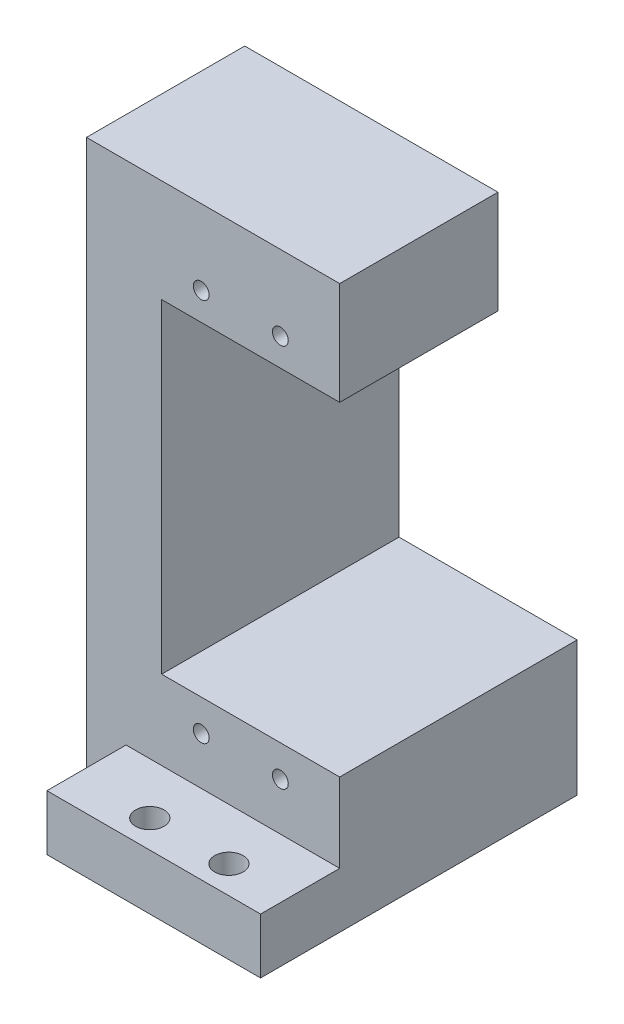
from build123d import *

# Parameters (mm, degrees)
SKETCH1_W           = 25
SKETCH1_H           = 40
BOSS_EXTRUDE1_DEPTH = 50
SKETCH2_W           = 22.5
SKETCH2_H           = 40
CUT_EXTRUDE1_DEPTH  = 25
SKETCH3_W           = 20
SKETCH3_H           = 10
CUT_EXTRUDE2_DEPTH  = 10
SKETCH5_R           = 1
CUT_EXTRUDE4_DEPTH  = 12
SKETCH6_W           = 25
SKETCH6_H           = 40
CUT_EXTRUDE5_DEPTH  = 8
SKETCH7_W           = 20
SKETCH7_H           = 22.5
CUT_EXTRUDE6_DEPTH  = 8
SKETCH8_R           = 1.8
CUT_EXTRUDE7_DEPTH  = 8
SKETCH12_W          = 10
SKETCH12_H          = 10
CUT_EXTRUDE9_DEPTH  = 10
SKETCH13_W          = 2.5
SKETCH13_H          = 40
BOSS_EXTRUDE2_DEPTH = 19
SKETCH14_W          = 40
SKETCH14_H          = 61
BOSS_EXTRUDE3_DEPTH = 2
SKETCH15_W          = 40
SKETCH15_H          = 3
BOSS_EXTRUDE4_DEPTH = 22.5
SKETCH16_W          = 10
SKETCH16_H          = 3
CUT_EXTRUDE10_DEPTH = 22.5
SKETCH17_W          = 10
SKETCH17_H          = 54
CUT_EXTRUDE11_DEPTH = 5.5
SKETCH18_W          = 27
SKETCH18_H          = 30
BOSS_EXTRUDE5_DEPTH = 10
SKETCH19_W          = 30
SKETCH19_H          = 71
BOSS_EXTRUDE6_DEPTH = 5
SKETCH20_W          = 32
SKETCH20_H          = 10
CUT_EXTRUDE12_DEPTH = 13


with BuildPart() as part:
    # Sketch1 → Boss-Extrude1 (new body)
    with BuildSketch(Plane(origin=(0, 0, 0), x_dir=(1, 0, 0), z_dir=(0, 1, 0))):
        with Locations((12.5, 20)):
            Rectangle(SKETCH1_W, SKETCH1_H)
    extrude(amount=BOSS_EXTRUDE1_DEPTH)

    # Sketch2 → Cut-Extrude1 (cut)
    with BuildSketch(Plane(origin=(0, 50, 0), x_dir=(1, 0, 0), z_dir=(0, 1, 0))):
        with Locations((13.75, 20)):
            Rectangle(SKETCH2_W, SKETCH2_H)
    extrude(amount=-CUT_EXTRUDE1_DEPTH, mode=Mode.SUBTRACT)

    # Sketch3 → Cut-Extrude2 (cut)
    with BuildSketch(Plane.XY):
        with Locations((12.5, 20)):
            Rectangle(SKETCH3_W, SKETCH3_H)
    extrude(amount=-CUT_EXTRUDE2_DEPTH, mode=Mode.SUBTRACT)

    # Sketch5 → Cut-Extrude4 (cut)
    with BuildSketch(Plane.XY.offset(-10)):
        with Locations((7.5, 21)):
            Circle(SKETCH5_R)
        with Locations((17.5, 21)):
            Circle(SKETCH5_R)
    cut_extrude4 = extrude(amount=-CUT_EXTRUDE4_DEPTH, mode=Mode.SUBTRACT)

    # Sketch6 → Cut-Extrude5 (cut)
    with BuildSketch(Plane.XZ):
        with Locations((12.5, -20)):
            Rectangle(SKETCH6_W, SKETCH6_H)
    extrude(amount=-CUT_EXTRUDE5_DEPTH, mode=Mode.SUBTRACT)

    # Sketch7 → Cut-Extrude6 (cut)
    with BuildSketch(Plane.XZ.offset(-8)):
        with Locations((12.5, -26.25)):
            Rectangle(SKETCH7_W, SKETCH7_H)
    extrude(amount=-CUT_EXTRUDE6_DEPTH, mode=Mode.SUBTRACT)

    # Sketch8 → Cut-Extrude7 (cut, through all)
    with BuildSketch(Plane(origin=(0, 15, 0), x_dir=(1, 0, 0), z_dir=(0, 1, 0))):
        with Locations((7.5, 3.5)):
            Circle(SKETCH8_R)
        with Locations((17.5, 3.5)):
            Circle(SKETCH8_R)
    extrude(amount=-CUT_EXTRUDE7_DEPTH, mode=Mode.SUBTRACT)

    # Sketch12 → Cut-Extrude9 (cut)
    with BuildSketch(Plane.ZY.offset(-22.5)):
        with Locations((-5, 20)):
            Rectangle(SKETCH12_W, SKETCH12_H)
    extrude(amount=-CUT_EXTRUDE9_DEPTH, mode=Mode.SUBTRACT)

    # Sketch13 → Boss-Extrude2 (add)
    with BuildSketch(Plane(origin=(0, 50, 0), x_dir=(1, 0, 0), z_dir=(0, 1, 0))):
        with Locations((1.25, 20)):
            Rectangle(SKETCH13_W, SKETCH13_H)
    extrude(amount=BOSS_EXTRUDE2_DEPTH)

    # Sketch14 → Boss-Extrude3 (add)
    with BuildSketch(Plane.ZY):
        with Locations((-20, 38.5)):
            Rectangle(SKETCH14_W, SKETCH14_H)
    extrude(amount=BOSS_EXTRUDE3_DEPTH)

    # Sketch15 → Boss-Extrude4 (add)
    with BuildSketch(Plane(origin=(2.5, 0, 0), x_dir=(0, 0, -1), z_dir=(1, 0, 0))):
        with Locations((20, 67.5)):
            Rectangle(SKETCH15_W, SKETCH15_H)
    extrude(amount=BOSS_EXTRUDE4_DEPTH)

    # Sketch16 → Cut-Extrude10 (cut)
    with BuildSketch(Plane(origin=(25, 0, 0), x_dir=(0, 0, -1), z_dir=(1, 0, 0))):
        with Locations((5, 67.5)):
            Rectangle(SKETCH16_W, SKETCH16_H)
    extrude(amount=-CUT_EXTRUDE10_DEPTH, mode=Mode.SUBTRACT)

    # Sketch17 → Cut-Extrude11 (cut, through all)
    with BuildSketch(Plane(origin=(2.5, 0, 0), x_dir=(0, 0, -1), z_dir=(1, 0, 0))):
        with Locations((5, 42)):
            Rectangle(SKETCH17_W, SKETCH17_H)
    extrude(amount=-CUT_EXTRUDE11_DEPTH, mode=Mode.SUBTRACT)

    # Sketch18 → Boss-Extrude5 (add)
    with BuildSketch(Plane(origin=(0, 69, 0), x_dir=(1, 0, 0), z_dir=(0, 1, 0))):
        with Locations((11.5, 25)):
            Rectangle(SKETCH18_W, SKETCH18_H)
    extrude(amount=BOSS_EXTRUDE5_DEPTH)

    # Mirror1: Cut-Extrude4 across plane
    add(cut_extrude4.mirror(Plane(origin=(0, 45.25, 0), x_dir=(0, 0, 1), z_dir=(0, -1, 0))), mode=Mode.SUBTRACT)

    # Sketch19 → Boss-Extrude6 (add)
    with BuildSketch(Plane.ZY.offset(2)):
        with Locations((-25, 43.5)):
            Rectangle(SKETCH19_W, SKETCH19_H)
    extrude(amount=BOSS_EXTRUDE6_DEPTH)

    # Sketch20 → Cut-Extrude12 (cut)
    with BuildSketch(Plane(origin=(0, 79, 0), x_dir=(1, 0, 0), z_dir=(0, 1, 0))):
        with Locations((9, 35)):
            Rectangle(SKETCH20_W, SKETCH20_H)
    extrude(amount=-CUT_EXTRUDE12_DEPTH, mode=Mode.SUBTRACT)


solid = part.part
